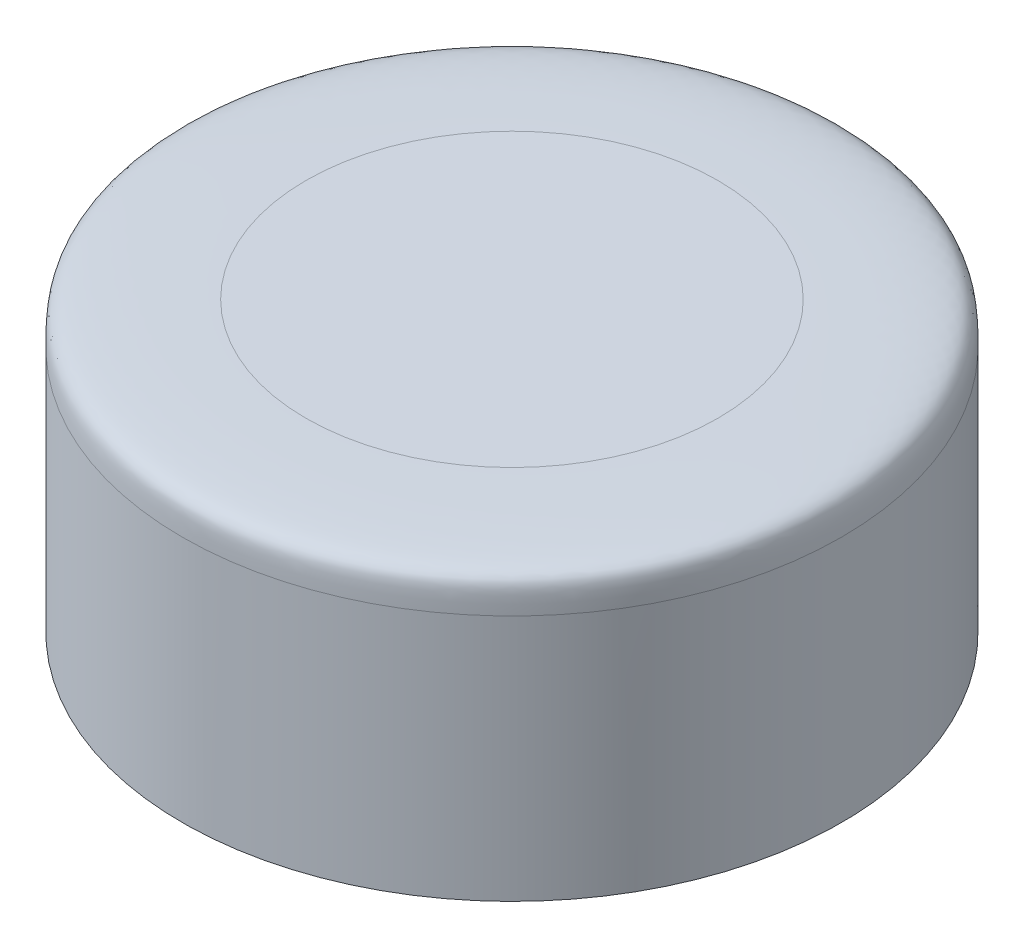
from build123d import *


with BuildPart() as part:
    # 草图1 → 旋转1 (revolve)
    with BuildSketch(Plane.XY):
        Polygon((0, 8), (8, 8), (8, 1), (3.9, 1), (3.9, 0.4), (2.9, 0.4), (2.9, 5.4), (0, 5.4), align=None)
    revolve(axis=Axis((0, 8, 0), (0, -1, 0)))

    # 草图2 → 切除-旋转1 (revolve, cut)
    with BuildSketch(Plane.XY):
        with BuildLine():
            Line((5, 8), (8, 8))
            Line((8, 8), (8, 7))
            add(Edge.make_bspline(
                [(5, 8), (5.693488859, 8), (7.464893787, 7.980007099), (7.989740211, 7.704714141), (8, 7.515407368), (8, 7)],
                knots=[0, 0, 0, 0, 0.50578806, 0.60578806, 1, 1, 1, 1], degree=3))
        make_face()
    revolve(axis=Axis((0, 0, 0), (0, -1, 0)), mode=Mode.SUBTRACT)


solid = part.part
